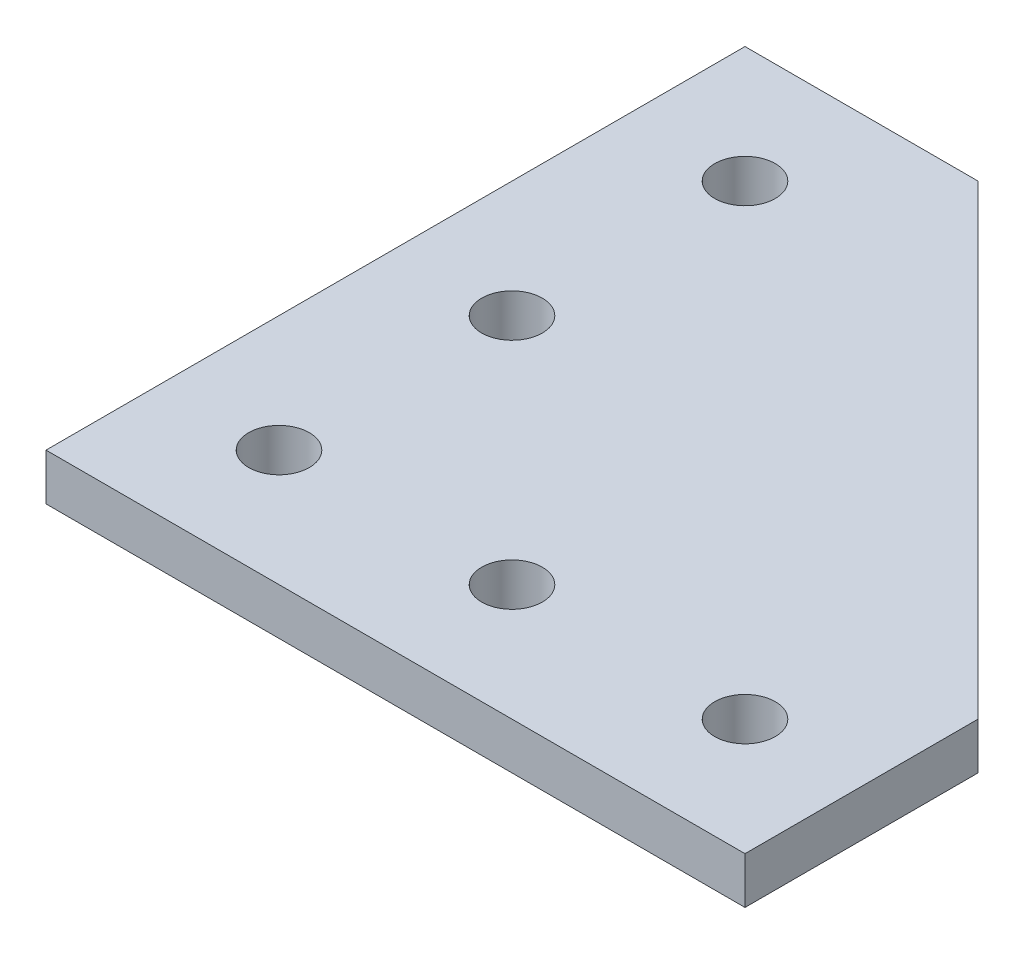
from build123d import *

# Parameters (mm, degrees)
SKETCH1_R           = 2.6
BOSS_EXTRUDE1_DEPTH = 4


with BuildPart() as part:
    # Sketch1 → Boss-Extrude1 (new body)
    with BuildSketch(Plane(origin=(0, 0, 0), x_dir=(1, 0, 0), z_dir=(0, 1, 0))):
        Polygon((0, 0), (60, 0), (60, 20), (20, 60), (0, 60), align=None)
        with Locations((10, 10)):
            Circle(SKETCH1_R, mode=Mode.SUBTRACT)
        with Locations((30, 10)):
            Circle(SKETCH1_R, mode=Mode.SUBTRACT)
        with Locations((50, 10)):
            Circle(SKETCH1_R, mode=Mode.SUBTRACT)
        with Locations((10, 30)):
            Circle(SKETCH1_R, mode=Mode.SUBTRACT)
        with Locations((10, 50)):
            Circle(SKETCH1_R, mode=Mode.SUBTRACT)
    extrude(amount=BOSS_EXTRUDE1_DEPTH)


solid = part.part
